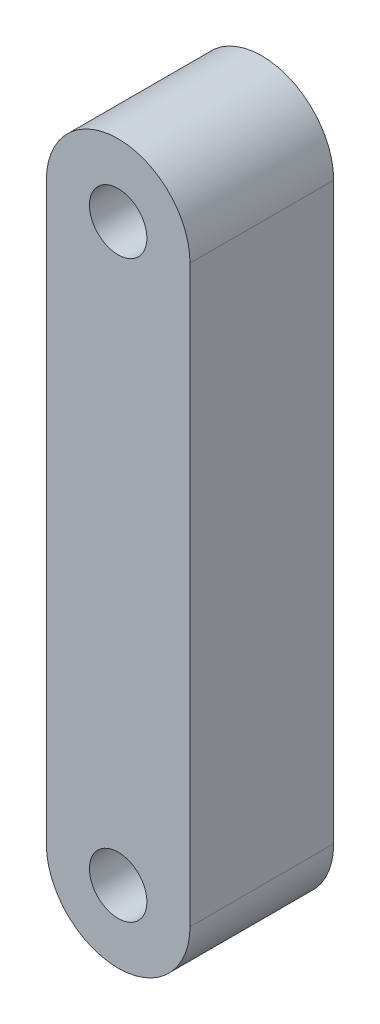
from build123d import *

# Parameters (mm, degrees)
CROQUIS1_R              = 2
SALIENTE_EXTRUIR1_DEPTH = 10


with BuildPart() as part:
    # Croquis1 → Saliente-Extruir1 (new body)
    with BuildSketch(Plane.XY):
        with BuildLine():
            Line((-5, 40), (-5, 0))
            ThreePointArc((-5, 0), (0, -5), (5, 0))
            Line((5, 0), (5, 40))
            ThreePointArc((5, 40), (0, 45), (-5, 40))
        make_face()
        Circle(CROQUIS1_R, mode=Mode.SUBTRACT)
        with Locations((0, 40)):
            Circle(CROQUIS1_R, mode=Mode.SUBTRACT)
    extrude(amount=SALIENTE_EXTRUIR1_DEPTH)


solid = part.part
